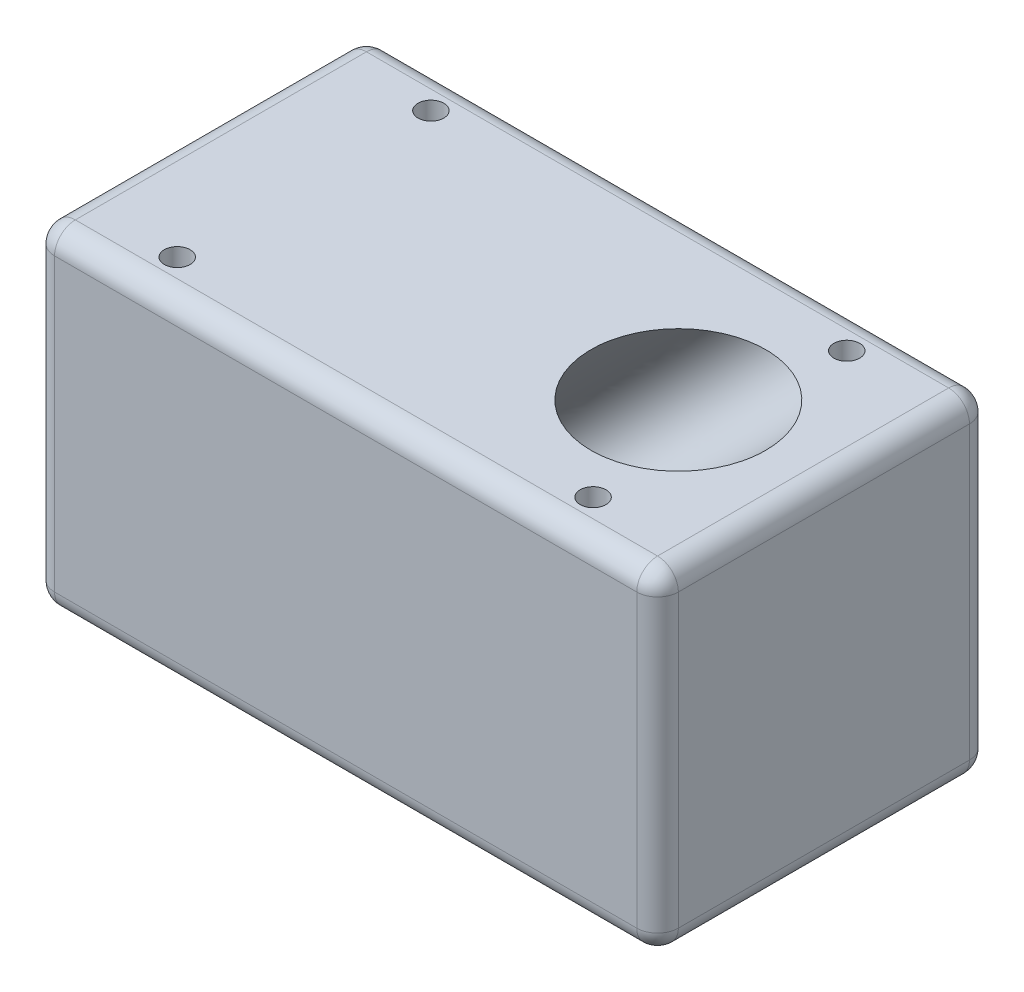
from build123d import *

# Parameters (mm, degrees)
SKETCH1_W           = 75
SKETCH1_H           = 40
BOSS_EXTRUDE1_DEPTH = 40
SKETCH2_R           = 10.5
CUT_EXTRUDE1_DEPTH  = 30
SKETCH3_R           = 1.55
CUT_EXTRUDE2_DEPTH  = 40
FILLET1_R           = 2.5
SKETCH6_R           = 10.5
SKETCH4_R           = 10.5


with BuildPart() as part:
    # Sketch1 → Boss-Extrude1 (new body)
    with BuildSketch(Plane(origin=(0, 0, 0), x_dir=(1, 0, 0), z_dir=(0, 1, 0))):
        Rectangle(SKETCH1_W, SKETCH1_H)
    extrude(amount=BOSS_EXTRUDE1_DEPTH)

    # Sketch2 → Cut-Extrude1 (cut)
    with BuildSketch(Plane.ZY.offset(37.5)):
        with Locations((0, 17.5)):
            Circle(SKETCH2_R)
    extrude(amount=-CUT_EXTRUDE1_DEPTH, mode=Mode.SUBTRACT)

    # Sketch3 → Cut-Extrude2 (cut)
    with BuildSketch(Plane(origin=(0, 40, 0), x_dir=(1, 0, 0), z_dir=(0, 1, 0))):
        with Locations((-25, 15.25)):
            Circle(SKETCH3_R)
        with Locations((25, 15.25)):
            Circle(SKETCH3_R)
        with Locations((-25, -15.25)):
            Circle(SKETCH3_R)
        with Locations((25, -15.25)):
            Circle(SKETCH3_R)
    extrude(amount=-CUT_EXTRUDE2_DEPTH, mode=Mode.SUBTRACT)

    # Fillet1
    fillet1_edges = [part.edges().sort_by_distance(p)[0] for p in [
        (-37.5, 40, 0),
        (-37.5, 17.5, -10.5),
        (0, 40, 20),
        (37.5, 40, 0),
        (0, 0, 20),
        (-37.5, 0, 0),
        (0, 0, -20),
        (37.5, 0, 0),
        (37.5, 20, 20),
        (-37.5, 20, 20),
        (-37.5, 20, -20),
        (37.5, 20, -20),
        (0, 40, -20),
    ]]
    fillet(fillet1_edges, radius=FILLET1_R)

    # Sketch6 → Cut-Loft1 section 0
    with BuildSketch(Plane(origin=(0, 0, 0), x_dir=(1, 0, 0), z_dir=(0, 1, 0))):
        with Locations((-20, 0)):
            Circle(SKETCH6_R)
    # Sketch4 → Cut-Loft1 section 1
    with BuildSketch(Plane(origin=(0, 40, 0), x_dir=(1, 0, 0), z_dir=(0, 1, 0))):
        with Locations((20, 0)):
            Circle(SKETCH4_R)
    loft(mode=Mode.SUBTRACT)


solid = part.part
